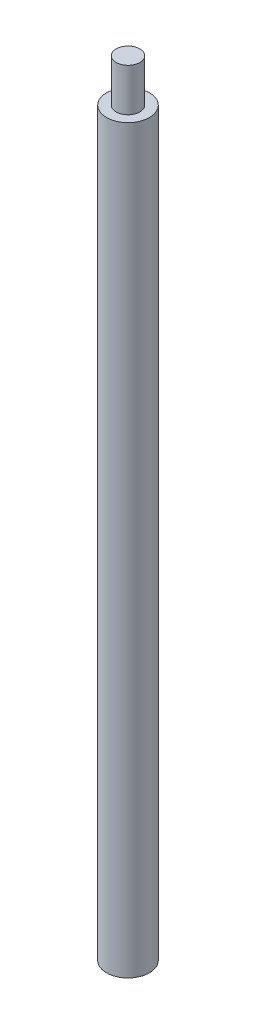
from build123d import *

# Parameters (mm, degrees)
SKETCH1_R                       = 3.175
BOSS_EXTRUDE1_DEPTH             = 109.728
F_6_32_TAPPED_HOLE1_D           = 2.7051
F_6_32_TAPPED_HOLE1_DEPTH       = 9.398
F_6_32_TAPPED_HOLE1_CBORE_D     = 3.5052
F_6_32_TAPPED_HOLE1_CBORE_DEPTH = 7.112
F_6_32_TAPPED_HOLE1_TIP         = 0.81269403
SKETCH4_R                       = 1.7526
BOSS_EXTRUDE2_DEPTH             = 6.35


with BuildPart() as part:
    # Sketch1 → Boss-Extrude1 (new body)
    with BuildSketch(Plane(origin=(0, 0, 0), x_dir=(1, 0, 0), z_dir=(0, 1, 0))):
        Circle(SKETCH1_R)
    extrude(amount=BOSS_EXTRUDE1_DEPTH)

    # #6-32 Tapped Hole1
    with Locations(Plane(origin=(0, 0, 0), x_dir=(-1, 0, 0), z_dir=(0, -1, 0))):
        with Locations((0, 0)):
            CounterBoreHole(F_6_32_TAPPED_HOLE1_D / 2, F_6_32_TAPPED_HOLE1_CBORE_D / 2, F_6_32_TAPPED_HOLE1_CBORE_DEPTH, depth=F_6_32_TAPPED_HOLE1_DEPTH)
            with Locations((0, 0, -(F_6_32_TAPPED_HOLE1_DEPTH + F_6_32_TAPPED_HOLE1_TIP / 2))):  # 118° drill point
                Cone(0, F_6_32_TAPPED_HOLE1_D / 2, F_6_32_TAPPED_HOLE1_TIP, mode=Mode.SUBTRACT)

    # Sketch4 → Boss-Extrude2 (add)
    with BuildSketch(Plane(origin=(0, 109.728, 0), x_dir=(1, 0, 0), z_dir=(0, 1, 0))):
        Circle(SKETCH4_R)
    extrude(amount=BOSS_EXTRUDE2_DEPTH)


solid = part.part
